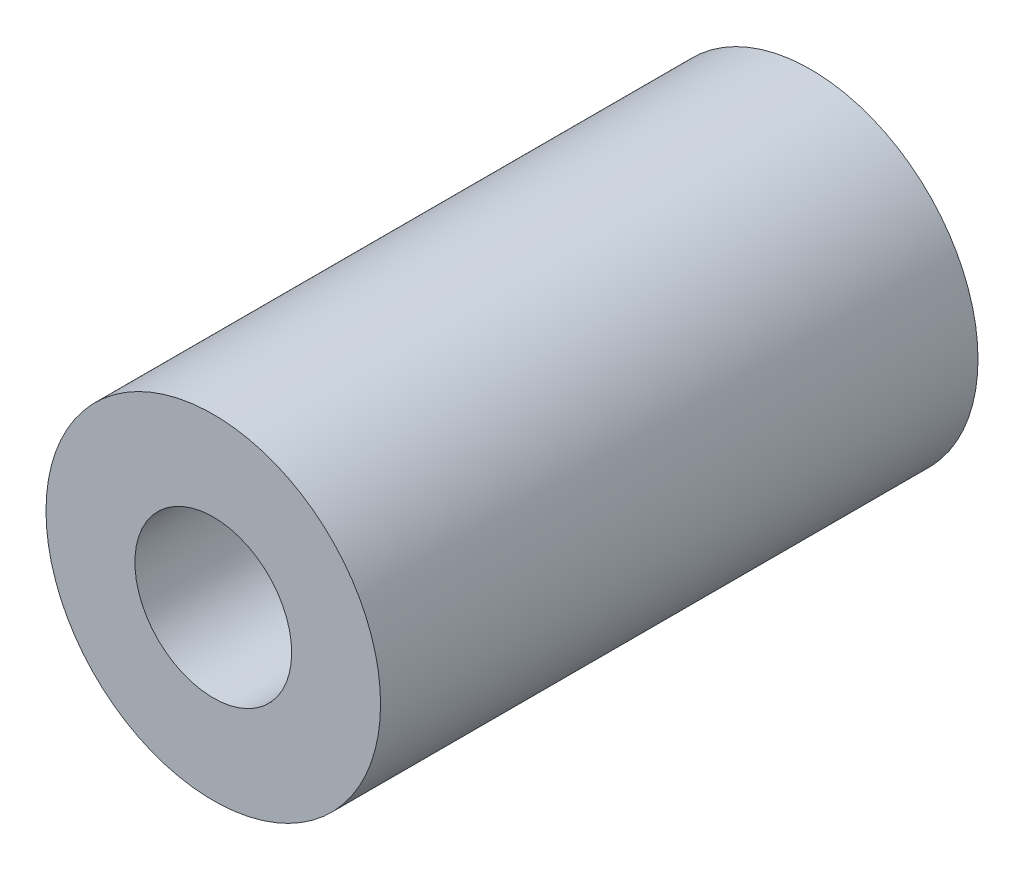
from build123d import *

# Parameters (mm, degrees)
SKETCH1_R           = 5.334
SKETCH1_R_2         = 2.38125
BOSS_EXTRUDE1_DEPTH = 19.05
SKETCH2_R           = 2.5
CUT_EXTRUDE1_DEPTH  = 9.525


with BuildPart() as part:
    # Sketch1 → Boss-Extrude1 (new body)
    with BuildSketch(Plane.XY):
        Circle(SKETCH1_R)
        Circle(SKETCH1_R_2, mode=Mode.SUBTRACT)
    extrude(amount=BOSS_EXTRUDE1_DEPTH)

    # Sketch2 → Cut-Extrude1 (cut, symmetric)
    with BuildSketch(Plane.XY.offset(19.05)):
        Circle(SKETCH2_R)
    extrude(amount=CUT_EXTRUDE1_DEPTH, both=True, mode=Mode.SUBTRACT)


solid = part.part
